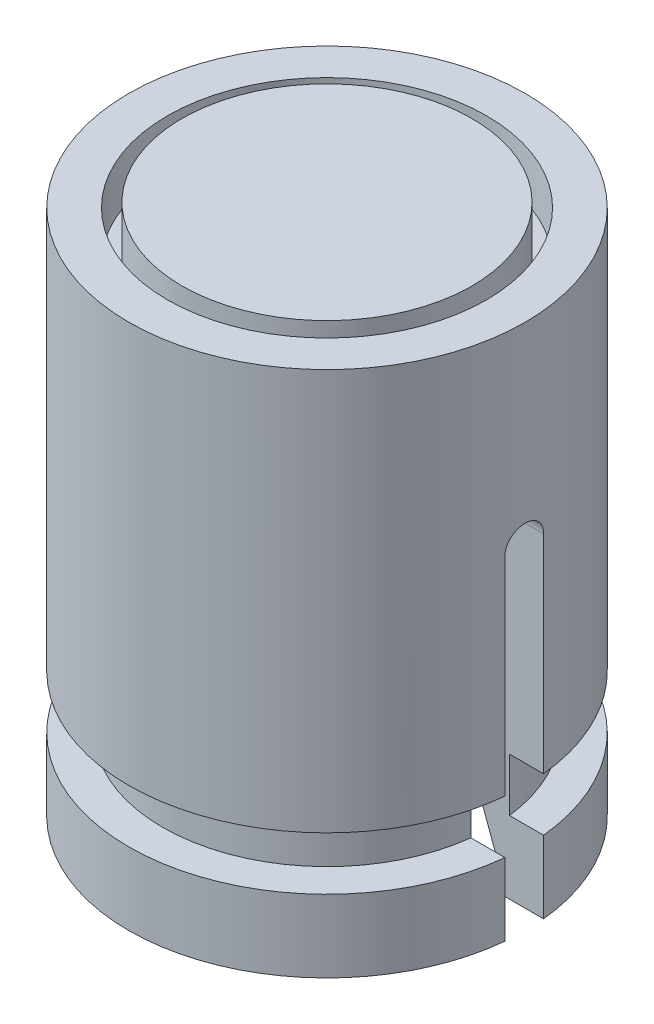
from build123d import *

# Parameters (mm, degrees)
WYTNIJ_WYCI_GNI_CIE1_DEPTH      = 5.1
WYTNIJ_WYCI_GNI_CIE1_DEPTH_BACK = 5.1


with BuildPart() as part:
    # Szkic2 → Obrót1 (revolve)
    with BuildSketch(Plane(origin=(0, 0, 0), x_dir=(0, 0, -1), z_dir=(1, 0, 0))):
        Polygon((-3.3, 10.9), (-3.3, 9.9), (-3, 9.9), (-3, 11), (0, 11), (0, 8.6), (-1.35, 8.6), (-1.35, 7.4), (-2.85, 7.4), (-2.85, 1.404592906), (-3.142847868, 0.6), (-3.142847868, 0), (-4.1, 0), (-4.1, 1.5), (-3.4, 1.5), (-3.4, 2.6), (-4.1, 2.6), (-4.1, 10.9), align=None)
    revolve(axis=Axis((0, 0, 0), (0, -1, 0)))

    # Szkic3 → Wytnij-wyciągnięcie1 (cut, two sides)
    with BuildSketch(Plane(origin=(0, 0, 0), x_dir=(0, 0, -1), z_dir=(1, 0, 0))) as wytnij_wyci_gni_cie1_sk:
        with BuildLine():
            Line((-0.4, 0), (-0.4, 6.9))
            ThreePointArc((-0.4, 6.9), (0, 7.3), (0.4, 6.9))
            Line((0.4, 6.9), (0.4, 0))
            Line((0.4, 0), (-0.4, 0))
        make_face()
    extrude(amount=WYTNIJ_WYCI_GNI_CIE1_DEPTH, mode=Mode.SUBTRACT)
    extrude(wytnij_wyci_gni_cie1_sk.sketch, amount=-WYTNIJ_WYCI_GNI_CIE1_DEPTH_BACK, mode=Mode.SUBTRACT)


solid = part.part
